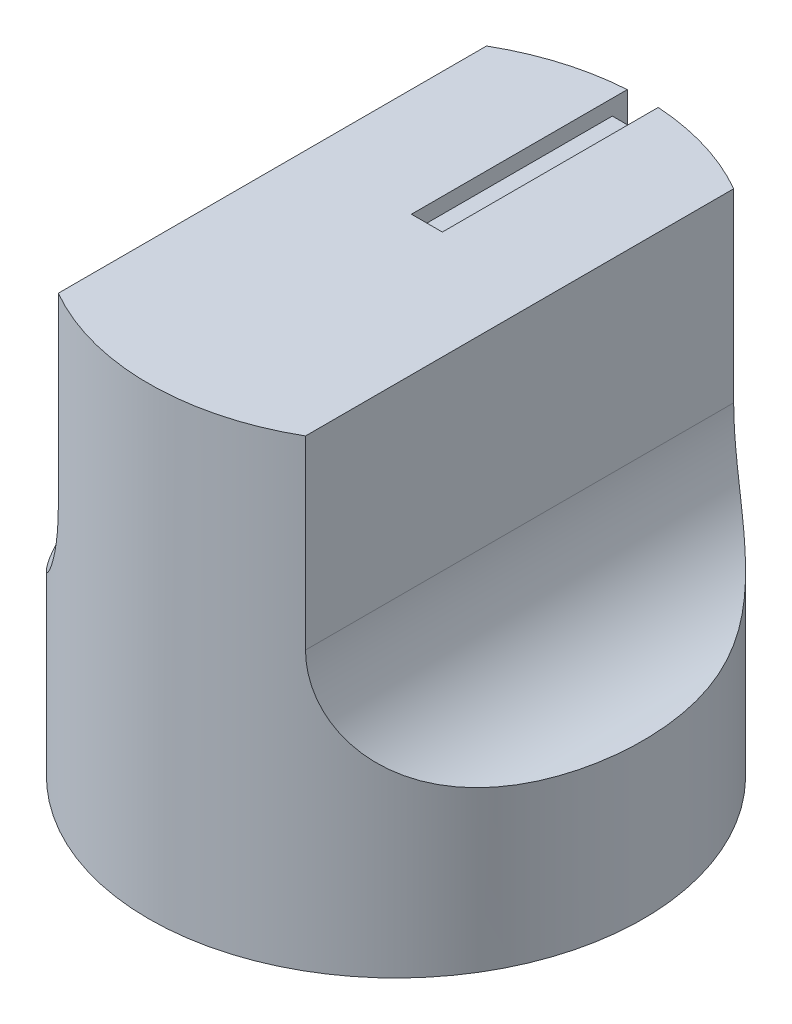
from build123d import *

# Parameters (mm, degrees)
SKETCH1_R           = 8
BOSS_EXTRUDE1_DEPTH = 15
CUT_EXTRUDE1_DEPTH  = 25
SKETCH3_R           = 3
CUT_EXTRUDE3_DEPTH  = 13
SKETCH3_3_R         = 6.5
SKETCH3_3_R_2       = 3.75
CUT_EXTRUDE4_DEPTH  = 3
SKETCH5_R           = 6.45
SKETCH5_R_2         = 3.8
BOSS_EXTRUDE2_DEPTH = 3
SKETCH6_W           = 1
SKETCH6_H           = 7
CUT_EXTRUDE5_DEPTH  = 0.5
SKETCH7_W           = 1
SKETCH7_H           = 14.5
CUT_EXTRUDE8_DEPTH  = 0.5


with BuildPart() as part:
    # Sketch1 → Boss-Extrude1 (new body)
    with BuildSketch(Plane(origin=(0, 0, 0), x_dir=(1, 0, 0), z_dir=(0, 1, 0))):
        Circle(SKETCH1_R)
    extrude(amount=BOSS_EXTRUDE1_DEPTH)

    # Sketch2 → Cut-Extrude1 (cut)
    with BuildSketch(Plane.XY.offset(10)):
        with BuildLine():
            Line((-4, 15), (-4, 9))
            ThreePointArc((-4, 9), (-5.171572875, 6.171572875), (-8, 5))
            Line((-8, 5), (-8, 15))
            Line((-8, 15), (-4, 15))
        make_face()
        with BuildLine():
            Line((4, 15), (4, 9))
            ThreePointArc((4, 9), (5.171572875, 6.171572875), (8, 5))
            Line((8, 5), (8, 15))
            Line((8, 15), (4, 15))
        make_face()
    extrude(amount=-CUT_EXTRUDE1_DEPTH, mode=Mode.SUBTRACT)

    # Sketch3 → Cut-Extrude3 (cut)
    with BuildSketch(Plane.XZ):
        Circle(SKETCH3_R)
    extrude(amount=-CUT_EXTRUDE3_DEPTH, mode=Mode.SUBTRACT)

    # Sketch3_3 → Cut-Extrude4 (cut)
    with BuildSketch(Plane.XZ):
        Circle(SKETCH3_3_R)
        Circle(SKETCH3_3_R_2, mode=Mode.SUBTRACT)
    extrude(amount=-CUT_EXTRUDE4_DEPTH, mode=Mode.SUBTRACT)

    # Sketch6 → Cut-Extrude5 (cut)
    with BuildSketch(Plane(origin=(0, 15, 0), x_dir=(1, 0, 0), z_dir=(0, 1, 0))):
        with Locations((0, 4.5)):
            Rectangle(SKETCH6_W, SKETCH6_H)
    extrude(amount=-CUT_EXTRUDE5_DEPTH, mode=Mode.SUBTRACT)

    # Sketch7 → Cut-Extrude8 (cut)
    with BuildSketch(Plane.XY.offset(-8)):
        with Locations((0, 7.25)):
            Rectangle(SKETCH7_W, SKETCH7_H)
    extrude(amount=CUT_EXTRUDE8_DEPTH, mode=Mode.SUBTRACT)


with BuildPart() as body_2:
    # Sketch5 → Boss-Extrude2 (new body)
    with BuildSketch(Plane.XZ):
        Circle(SKETCH5_R)
        Circle(SKETCH5_R_2, mode=Mode.SUBTRACT)
    extrude(amount=-BOSS_EXTRUDE2_DEPTH)


solid = Compound([part.part, body_2.part])
